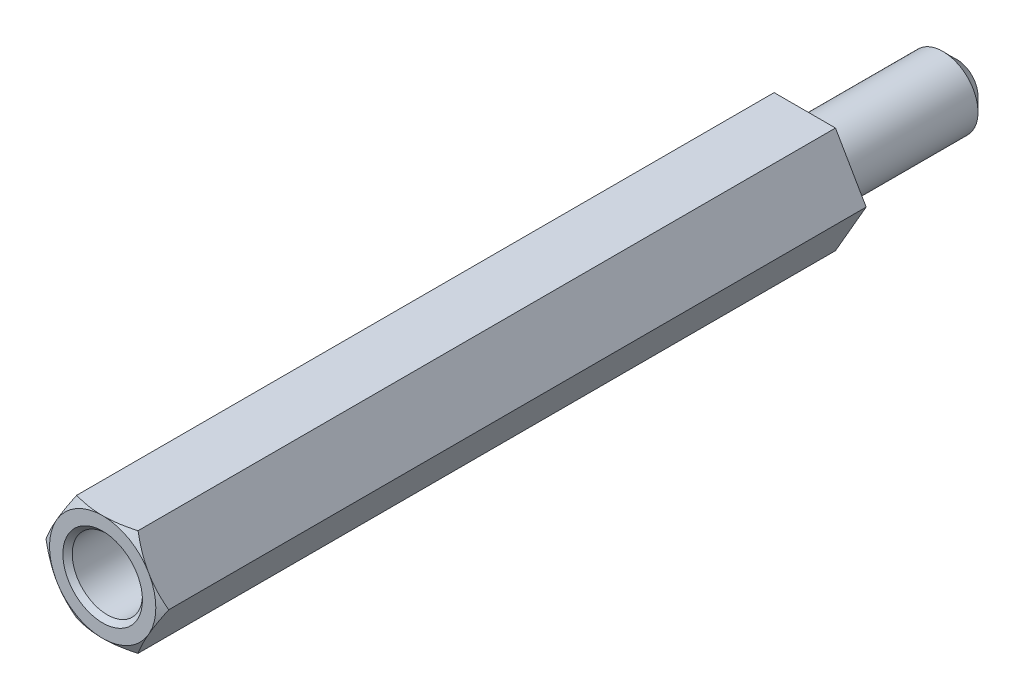
from build123d import *

# Parameters (mm, degrees)
BOSS_EXTRUDE1_DEPTH     = 30
SKETCH2_R               = 1.5
CUT_EXTRUDE1_DEPTH      = 1
CUT_EXTRUDE1_DEPTH_BACK = 12
CHAMFER1_SIZE           = 0.2
SKETCH4_R               = 1.5
BOSS_EXTRUDE2_DEPTH     = 6.5
CHAMFER2_SIZE           = 0.6


with BuildPart() as part:
    # Sketch1 → Boss-Extrude1 (new body)
    with BuildSketch(Plane.XY):
        Polygon((2.621170222, 0), (1.310585111, 2.27), (-1.310585111, 2.27), (-2.621170222, 0), (-1.310585111, -2.27), (1.310585111, -2.27), align=None)
    extrude(amount=BOSS_EXTRUDE1_DEPTH)

    # Sketch2 → Cut-Extrude1 (cut, two sides)
    with BuildSketch(Plane.XY.offset(30)) as cut_extrude1_sk:
        Circle(SKETCH2_R)
    extrude(amount=CUT_EXTRUDE1_DEPTH, mode=Mode.SUBTRACT)
    extrude(cut_extrude1_sk.sketch, amount=-CUT_EXTRUDE1_DEPTH_BACK, mode=Mode.SUBTRACT)

    # Sketch3 → Cut-Revolve1 (revolve, cut)
    with BuildSketch(Plane(origin=(0, 0, 0), x_dir=(1, 0, 0), z_dir=(0, 1, 0))):
        Polygon((-2.621170222, -30), (-2.271170222, -30), (-2.621170222, -29.8), align=None)
    revolve(axis=Axis((0, 0, 18), (0, 0, 1)), mode=Mode.SUBTRACT)

    # Chamfer1
    chamfer1_edges = [part.edges().sort_by_distance(p)[0] for p in [
        (-1.5, 0, 30),
    ]]
    chamfer(chamfer1_edges, length=CHAMFER1_SIZE)

    # Sketch4 → Boss-Extrude2 (add)
    with BuildSketch(Plane(origin=(0, 0, 0), x_dir=(-1, 0, 0), z_dir=(0, 0, -1))):
        Circle(SKETCH4_R)
    extrude(amount=BOSS_EXTRUDE2_DEPTH)

    # Chamfer2
    chamfer2_edges = [part.edges().sort_by_distance(p)[0] for p in [
        (1.5, 0, -6.5),
    ]]
    chamfer(chamfer2_edges, length=CHAMFER2_SIZE)


solid = part.part
